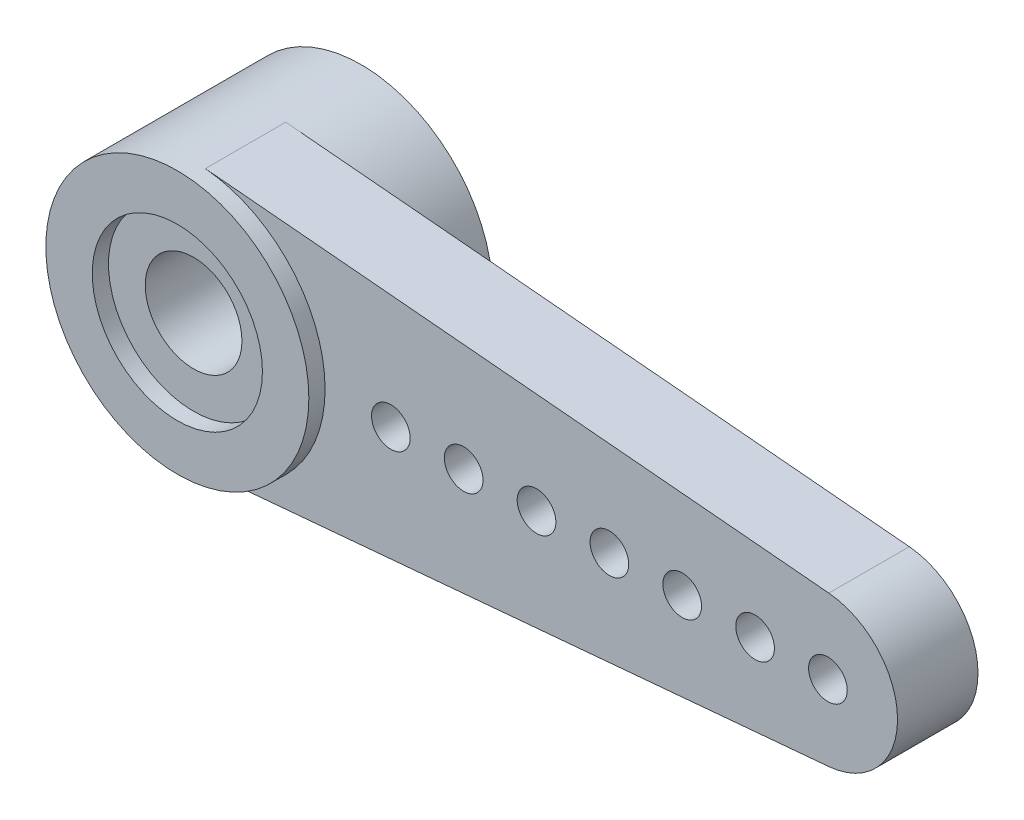
from build123d import *
from build123d.topology import SkipClean

# Parameters (mm, degrees)
SKETCH1_R             = 0.5
SKETCH1_R_2           = 1.25
BASE_DEPTH            = 2.08
CONNECTION_DEPTH      = 2.5
CONNECTION_DEPTH_BACK = 2.25
SKETCH1_3_R           = 2.2


with BuildPart() as part:
    # Sketch1 → Base (new body)
    with BuildSketch(Plane.XY):
        with BuildLine():
            ThreePointArc((16.424, -1.942221409), (18.2, 0), (16.424, 1.942221409))
            Line((16.424, 1.942221409), (0.303384615, 3.386437328))
            ThreePointArc((0.303384615, 3.386437328), (-3.4, 0), (0.303384615, -3.386437328))
            Line((0.303384615, -3.386437328), (16.424, -1.942221409))
        make_face()
        with Locations((5.1, 0)):
            Circle(SKETCH1_R, mode=Mode.SUBTRACT)
        with Locations((6.983333333, 0)):
            Circle(SKETCH1_R, mode=Mode.SUBTRACT)
        with Locations((8.866666667, 0)):
            Circle(SKETCH1_R, mode=Mode.SUBTRACT)
        with Locations((10.75, 0)):
            Circle(SKETCH1_R, mode=Mode.SUBTRACT)
        with Locations((12.633333333, 0)):
            Circle(SKETCH1_R, mode=Mode.SUBTRACT)
        with Locations((14.516666667, 0)):
            Circle(SKETCH1_R, mode=Mode.SUBTRACT)
        with Locations((16.4, 0)):
            Circle(SKETCH1_R, mode=Mode.SUBTRACT)
        Circle(SKETCH1_R_2, mode=Mode.SUBTRACT)
    extrude(amount=BASE_DEPTH)

    # Sketch1_3 → Connection (add, two sides: drawn at the far end of the back side and taken through both)
    with SkipClean():  # the faces are left unmerged after this step: merging them gives an invalid solid
        with BuildSketch(Plane.XY.offset(-CONNECTION_DEPTH_BACK)):
            with BuildLine():
                ThreePointArc((3.4, 0), (2.509134083, 2.294394507), (0.303384615, 3.386437328))
                ThreePointArc((0.303384615, 3.386437328), (-3.4, 0), (0.303384615, -3.386437328))
                ThreePointArc((0.303384615, -3.386437328), (2.509134083, -2.294394507), (3.4, 0))
            make_face()
            Circle(SKETCH1_3_R, mode=Mode.SUBTRACT)
        extrude(amount=CONNECTION_DEPTH + CONNECTION_DEPTH_BACK)


solid = part.part
